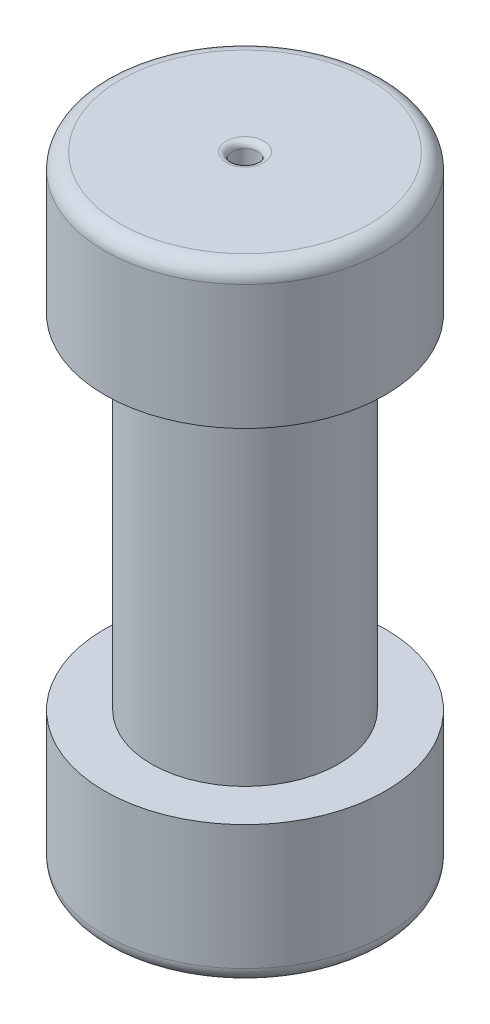
from build123d import *

# Parameters (mm, degrees)
SKETCH1_R           = 22.86
BOSS_EXTRUDE1_DEPTH = 22.86
SKETCH3_R           = 15.24
BOSS_EXTRUDE2_DEPTH = 55.88
SKETCH4_R           = 22.86
BOSS_EXTRUDE3_DEPTH = 22.86
FILLET3_R           = 2.54
SKETCH5_R           = 2.055
CUT_EXTRUDE1_DEPTH  = 7.62
SKETCH8_W           = 3.7
SKETCH8_H           = 3.4
CUT_EXTRUDE2_DEPTH  = 85
FILLET4_R           = 1


with BuildPart() as part:
    # Sketch1 → Boss-Extrude1 (new body)
    with BuildSketch(Plane(origin=(0, 0, 0), x_dir=(1, 0, 0), z_dir=(0, 1, 0))):
        Circle(SKETCH1_R)
    extrude(amount=BOSS_EXTRUDE1_DEPTH)

    # Sketch3 → Boss-Extrude2 (add)
    with BuildSketch(Plane(origin=(0, 22.86, 0), x_dir=(1, 0, 0), z_dir=(0, 1, 0))):
        Circle(SKETCH3_R)
    extrude(amount=BOSS_EXTRUDE2_DEPTH)

    # Sketch4 → Boss-Extrude3 (add)
    with BuildSketch(Plane(origin=(0, 78.74, 0), x_dir=(1, 0, 0), z_dir=(0, 1, 0))):
        Circle(SKETCH4_R)
    extrude(amount=BOSS_EXTRUDE3_DEPTH)

    # Fillet3
    fillet3_edges = [part.edges().sort_by_distance(p)[0] for p in [
        (-22.86, 101.6, 0),
        (-22.86, 0, 0),
    ]]
    fillet(fillet3_edges, radius=FILLET3_R)

    # Sketch5 → Cut-Extrude1 (cut)
    with BuildSketch(Plane(origin=(0, 101.6, 0), x_dir=(1, 0, 0), z_dir=(0, 1, 0))):
        Circle(SKETCH5_R)
    extrude(amount=-CUT_EXTRUDE1_DEPTH, mode=Mode.SUBTRACT)

    # Sketch8 → Cut-Extrude2 (cut)
    with BuildSketch(Plane.XZ):
        Rectangle(SKETCH8_W, SKETCH8_H)
    extrude(amount=-CUT_EXTRUDE2_DEPTH, mode=Mode.SUBTRACT)

    # Fillet4
    fillet4_edges = [part.edges().sort_by_distance(p)[0] for p in [
        (-2.055, 101.6, 0),
        (-1.85, 0, 0),
        (0, 0, -1.7),
        (1.85, 0, 0),
        (0, 0, 1.7),
    ]]
    fillet(fillet4_edges, radius=FILLET4_R)


solid = part.part
